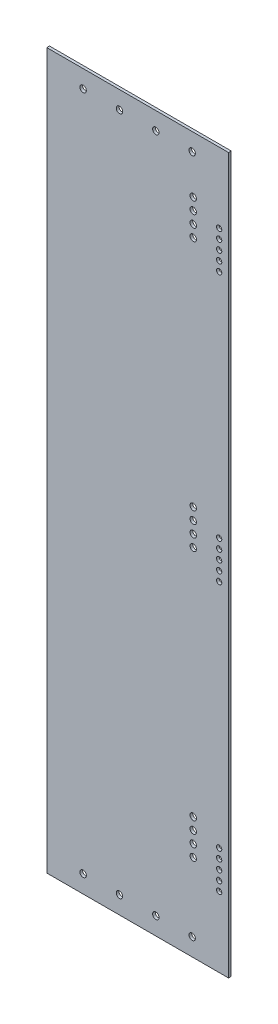
from build123d import *

# Parameters (mm, degrees)
SKETCH1_W            = 155
SKETCH1_H            = 609.6
BOSS_EXTRUDE1_DEPTH  = 2.305
M4_CLEARANCE_HOLE1_D = 4.5
M5_CLEARANCE_HOLE1_D = 5.5


with BuildPart() as part:
    # Sketch1 → Boss-Extrude1 (new body)
    with BuildSketch(Plane.XY):
        Rectangle(SKETCH1_W, SKETCH1_H)
    extrude(amount=BOSS_EXTRUDE1_DEPTH)

    # M4 Clearance Hole1 (through all)
    with Locations(Plane.XY.offset(2.305)):
        with Locations((69.5, 228.8), (69.5, 244.8), (69.5, 236.8), (69.5, 220.8), (69.5, 212.8), (69.5, 16), (69.5, 8), (69.5, 0), (69.5, -8), (69.5, -16), (69.5, -212.8), (69.5, -220.8), (69.5, -228.8), (69.5, -236.8), (69.5, -244.8)):
            Hole(M4_CLEARANCE_HOLE1_D / 2)

    # M5 Clearance Hole1 (through all)
    with Locations(Plane.XY.offset(2.305)):
        with Locations((-46.5, -289.795), (-15.5, -289.795), (15.5, -289.795), (46.5, -289.795), (-46.5, 289.795), (-15.5, 289.795), (15.5, 289.795), (46.5, 289.795), (47.4, -230.8), (47.4, -220.8), (47.4, -210.8), (47.4, -200.8), (47.4, -2), (47.4, 8), (47.4, 18), (47.4, 28), (47.4, 226.8), (47.4, 236.8), (47.4, 246.8), (47.4, 256.8)):
            Hole(M5_CLEARANCE_HOLE1_D / 2)


solid = part.part
